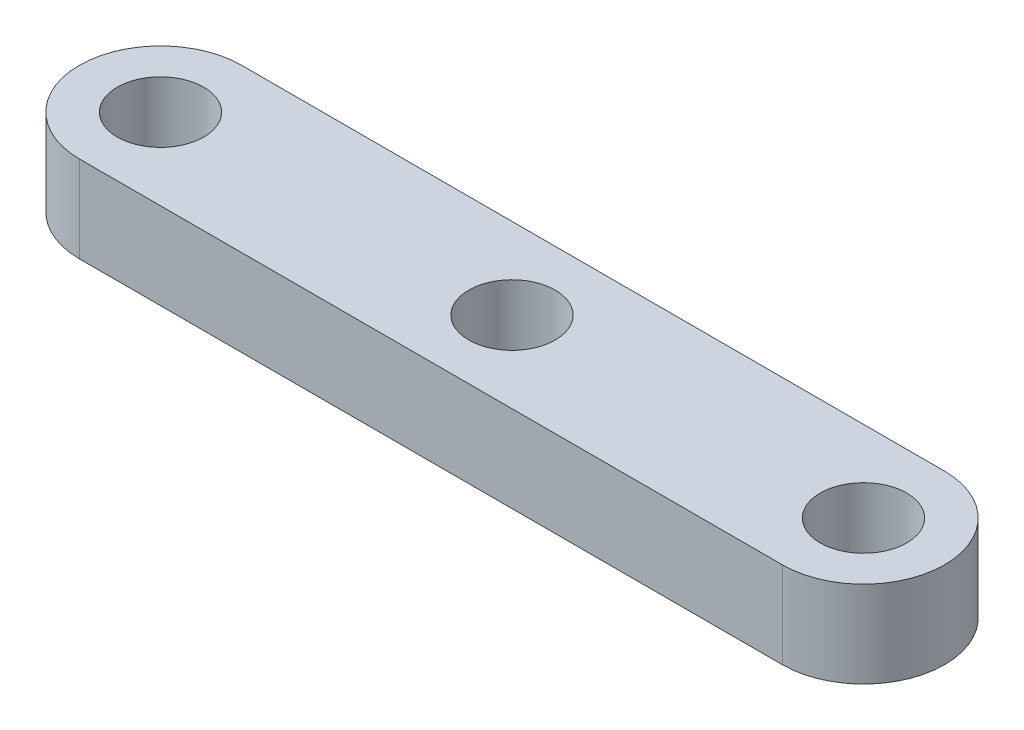
from build123d import *

# Parameters (mm, degrees)
SKETCH1_R           = 2
BOSS_EXTRUDE1_DEPTH = 4


with BuildPart() as part:
    # Sketch1 → Boss-Extrude1 (new body)
    with BuildSketch(Plane(origin=(0, 0, 0), x_dir=(1, 0, 0), z_dir=(0, 1, 0))):
        with BuildLine():
            Line((0, 3.75), (32.5, 3.75))
            ThreePointArc((32.5, 3.75), (36.25, 0), (32.5, -3.75))
            Line((32.5, -3.75), (0, -3.75))
            ThreePointArc((0, -3.75), (-3.75, 0), (0, 3.75))
        make_face()
        Circle(SKETCH1_R, mode=Mode.SUBTRACT)
        with Locations((16.25, 0)):
            Circle(SKETCH1_R, mode=Mode.SUBTRACT)
        with Locations((32.5, 0)):
            Circle(SKETCH1_R, mode=Mode.SUBTRACT)
    extrude(amount=BOSS_EXTRUDE1_DEPTH)


solid = part.part
